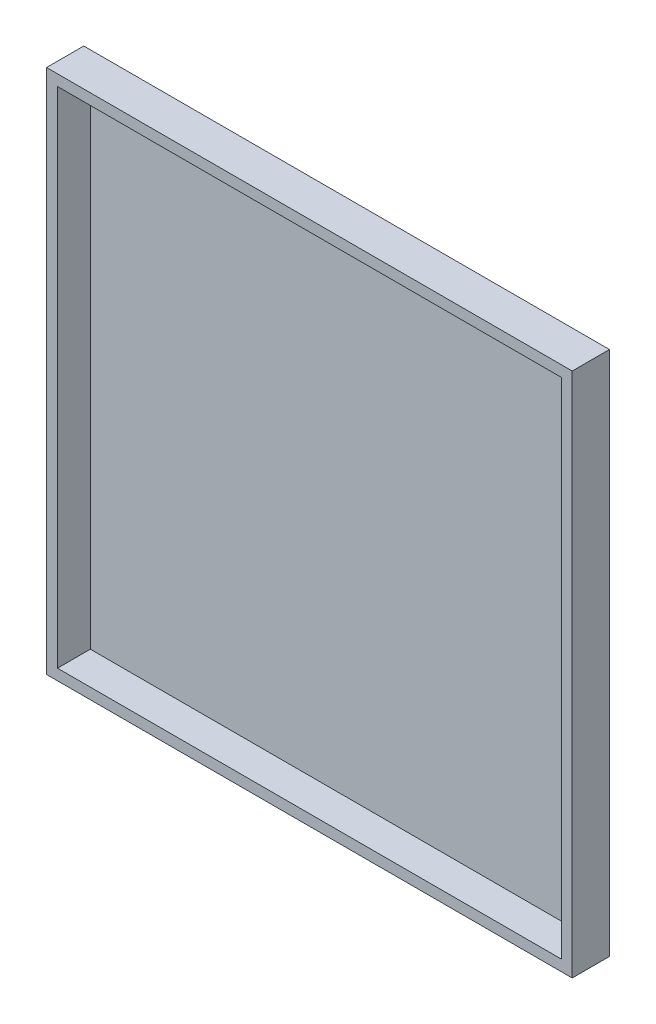
from build123d import *

# Parameters (mm, degrees)
SKETCH1_W           = 2400
SKETCH1_H           = 2400
BOSS_EXTRUDE1_DEPTH = 20
SKETCH2_W           = 2400
SKETCH2_H           = 2400
SKETCH2_W_2         = 2300
SKETCH2_H_2         = 2300
BOSS_EXTRUDE2_DEPTH = 150


with BuildPart() as part:
    # Sketch1 → Boss-Extrude1 (new body)
    with BuildSketch(Plane.XY):
        Rectangle(SKETCH1_W, SKETCH1_H)
    extrude(amount=BOSS_EXTRUDE1_DEPTH)

    # Sketch2 → Boss-Extrude2 (add)
    with BuildSketch(Plane.XY.offset(20)):
        Rectangle(SKETCH2_W, SKETCH2_H)
        Rectangle(SKETCH2_W_2, SKETCH2_H_2, mode=Mode.SUBTRACT)
    extrude(amount=BOSS_EXTRUDE2_DEPTH)


solid = part.part
